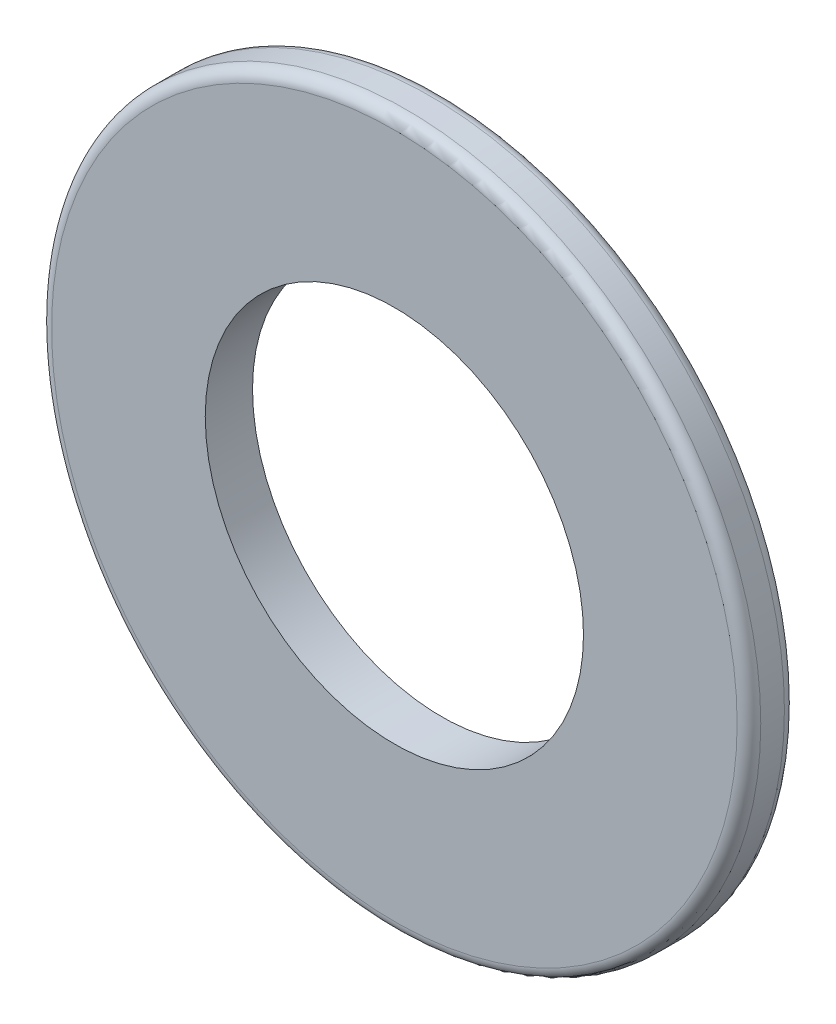
from build123d import *

# Parameters (mm, degrees)
SKETCH1_R           = 7.5
SKETCH1_R_2         = 4
BOSS_EXTRUDE1_DEPTH = 1
FILLET1_R           = 0.25


with BuildPart() as part:
    # Sketch1 → Boss-Extrude1 (new body)
    with BuildSketch(Plane.XY):
        Circle(SKETCH1_R)
        Circle(SKETCH1_R_2, mode=Mode.SUBTRACT)
    extrude(amount=BOSS_EXTRUDE1_DEPTH)

    # Fillet1
    fillet1_edges = [part.edges().sort_by_distance(p)[0] for p in [
        (-7.5, 0, 0),
        (-7.5, 0, 1),
    ]]
    fillet(fillet1_edges, radius=FILLET1_R)


solid = part.part
